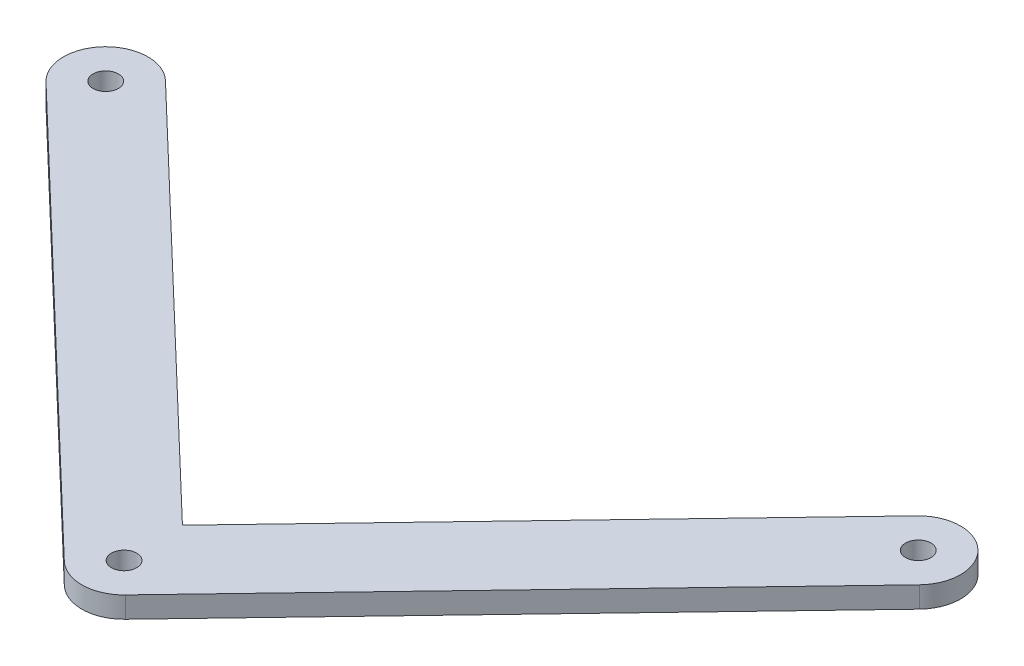
from build123d import *

# Parameters (mm, degrees)
SKETCH1_R           = 3
BOSS_EXTRUDE2_DEPTH = 5


with BuildPart() as part:
    # Sketch1 → Boss-Extrude2 (new body)
    with BuildSketch(Plane(origin=(0, 0, 0), x_dir=(1, 0, 0), z_dir=(0, 1, 0))):
        with BuildLine():
            Line((-107.345005718, 88.870972468), (-6.913400561, -7.225295335))
            ThreePointArc((-6.913400561, -7.225295335), (0.220534203, -9.997567938), (7.225283293, -6.913413146))
            Line((7.225283293, -6.913413146), (99.173678137, 89.182854657))
            ThreePointArc((99.173678137, 89.182854657), (98.86180799, 103.321551097), (84.72311155, 103.009680949))
            Line((84.72311155, 103.009680949), (-0.311882189, 14.138683855))
            Line((-0.311882189, 14.138683855), (-93.518204595, 103.321563138))
            ThreePointArc((-93.518204595, 103.321563138), (-107.656900491, 103.009668365), (-107.345005718, 88.870972468))
        make_face()
        with Locations((-100.431605156, 96.096267803)):
            Circle(SKETCH1_R, mode=Mode.SUBTRACT)
        with Locations((91.948394844, 96.096267803)):
            Circle(SKETCH1_R, mode=Mode.SUBTRACT)
        Circle(SKETCH1_R, mode=Mode.SUBTRACT)
    extrude(amount=BOSS_EXTRUDE2_DEPTH)


solid = part.part
